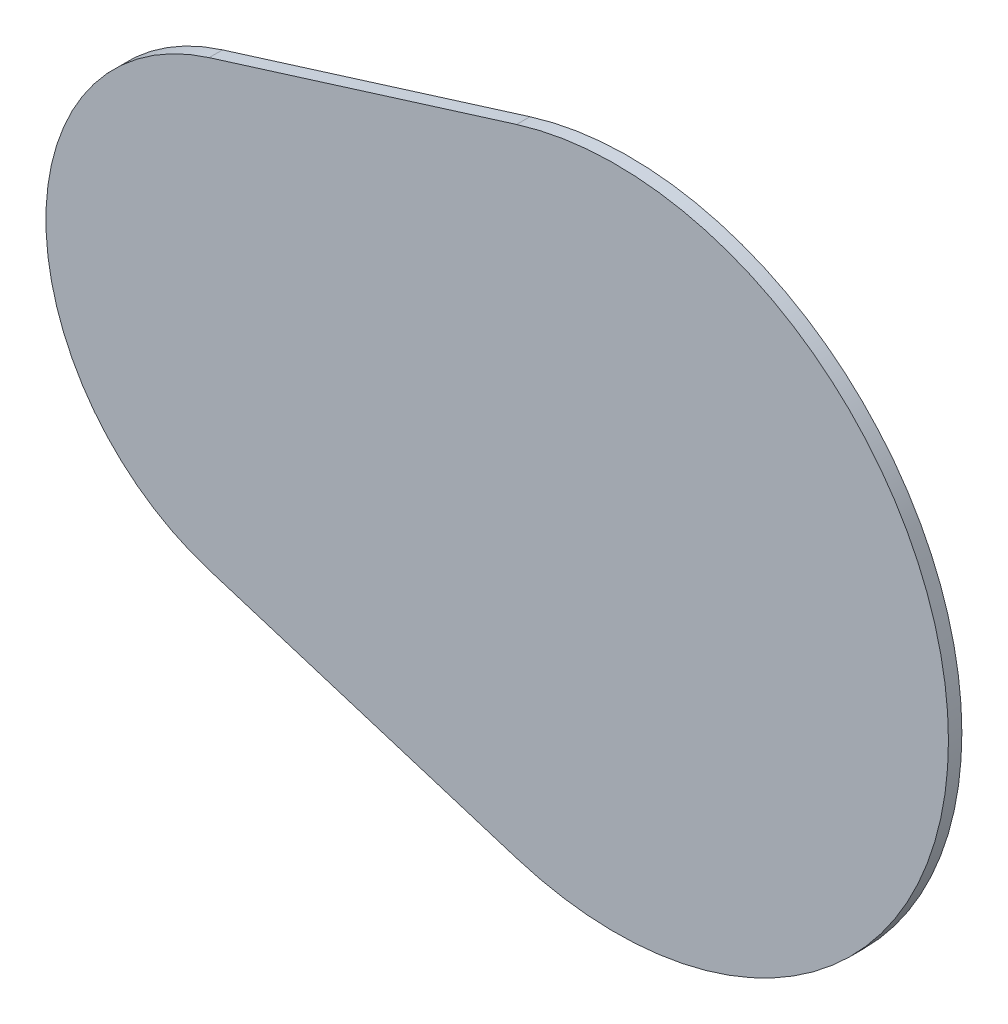
from build123d import *

# Parameters (mm, degrees)
BOSS_EXTRUDE1_DEPTH = 1.5875


with BuildPart() as part:
    # Sketch1 → Boss-Extrude1 (new body)
    with BuildSketch(Plane.XY):
        with BuildLine():
            Line((-11.71824382, -37.585631055), (-48.091435163, -26.2453951))
            ThreePointArc((-48.091435163, -26.2453951), (-67.400177515, 0), (-48.091435163, 26.2453951))
            Line((-48.091435163, 26.2453951), (-11.71824382, 37.585631055))
            ThreePointArc((-11.71824382, 37.585631055), (39.37, 0), (-11.71824382, -37.585631055))
        make_face()
    extrude(amount=BOSS_EXTRUDE1_DEPTH)


solid = part.part
